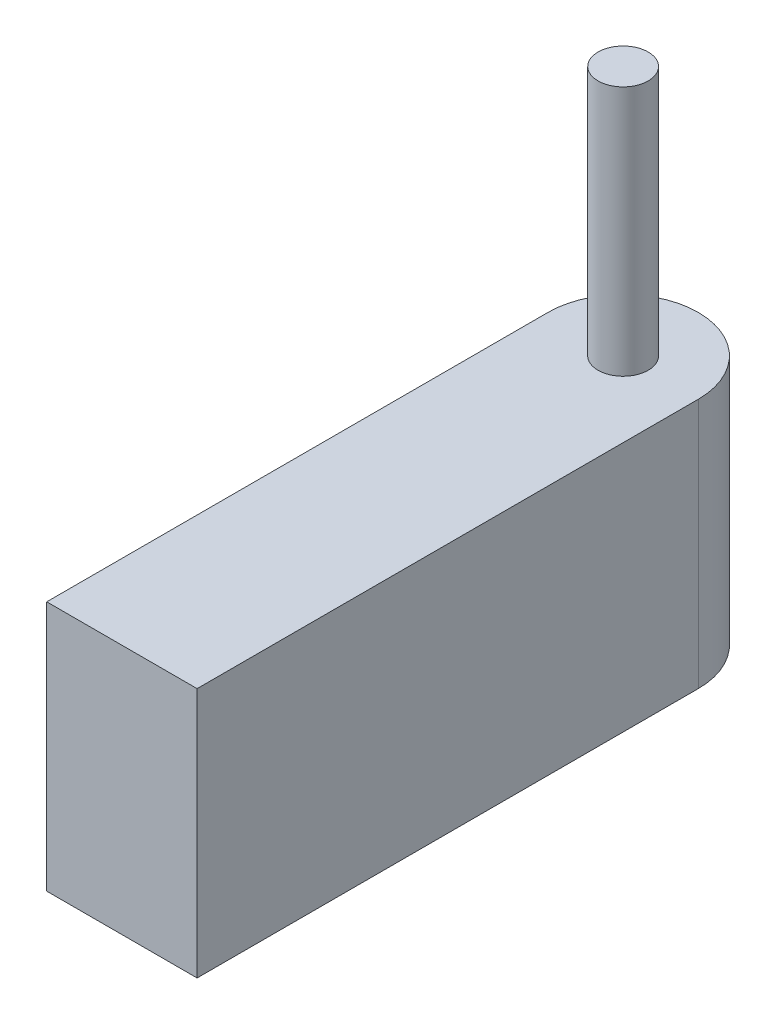
from build123d import *

# Parameters (mm, degrees)
BOSS_EXTRUDE1_DEPTH = 1.27
SKETCH1_4_R         = 0.127
BOSS_EXTRUDE2_DEPTH = 2.54


with BuildPart() as part:
    # Sketch1 → Boss-Extrude1 (new body)
    with BuildSketch(Plane(origin=(0, 0, 0), x_dir=(1, 0, 0), z_dir=(0, 1, 0))):
        with BuildLine():
            Line((-0.381, 1.27), (-0.381, -1.27))
            Line((-0.381, -1.27), (0.381, -1.27))
            Line((0.381, -1.27), (0.381, 1.27))
            ThreePointArc((0.381, 1.27), (0, 1.651), (-0.381, 1.27))
        make_face()
    extrude(amount=BOSS_EXTRUDE1_DEPTH)

    # Sketch1_4 → Boss-Extrude2 (add)
    with BuildSketch(Plane(origin=(0, 0, 0), x_dir=(1, 0, 0), z_dir=(0, 1, 0))):
        with Locations((0, 1.27)):
            Circle(SKETCH1_4_R)
    extrude(amount=BOSS_EXTRUDE2_DEPTH)


solid = part.part
